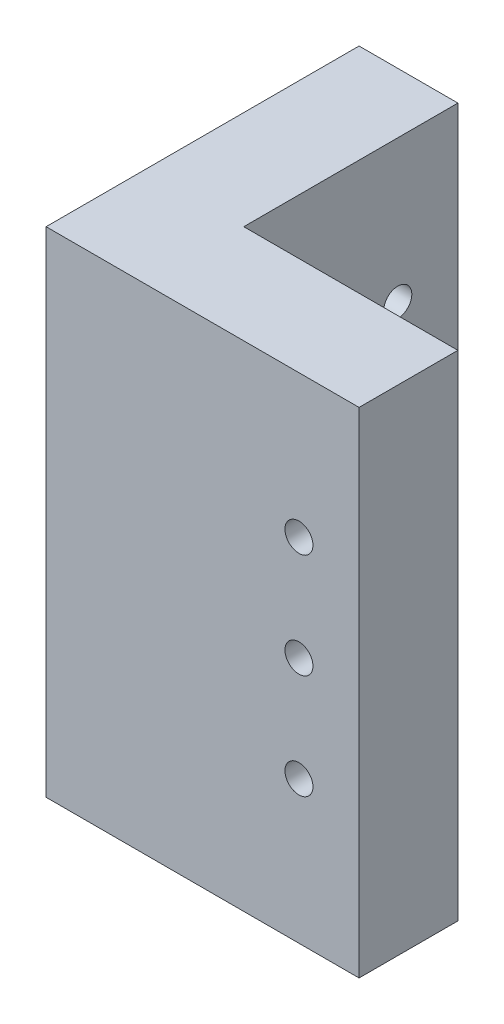
from build123d import *

# Parameters (mm, degrees)
BOSS_EXTRUDE1_DEPTH = 15
SKETCH2_R           = 0.85
CUT_EXTRUDE1_DEPTH  = 20


with BuildPart() as part:
    # Sketch1 → Boss-Extrude1 (new body, symmetric)
    with BuildSketch(Plane(origin=(0, 0, 0), x_dir=(1, 0, 0), z_dir=(0, 1, 0))):
        Polygon((-3, 10), (-3, -3), (10, -3), (10, -9), (-9, -9), (-9, 10), align=None)
    extrude(amount=BOSS_EXTRUDE1_DEPTH, both=True)

    # Sketch2 → Cut-Extrude1 (cut, through all)
    with BuildSketch(Plane.XY.offset(9)):
        with Locations((6.35, 6.35)):
            Circle(SKETCH2_R)
        with Locations((6.35, 0)):
            Circle(SKETCH2_R)
        with Locations((6.35, -6.35)):
            Circle(SKETCH2_R)
    cut_extrude1 = extrude(amount=-CUT_EXTRUDE1_DEPTH, mode=Mode.SUBTRACT)

    # Mirror1: Cut-Extrude1 across plane
    add(cut_extrude1.mirror(Plane(origin=(0, 0, 0), x_dir=(-0.707106781, 0, 0.707106781), z_dir=(0.707106781, 0, 0.707106781))), mode=Mode.SUBTRACT)


solid = part.part
